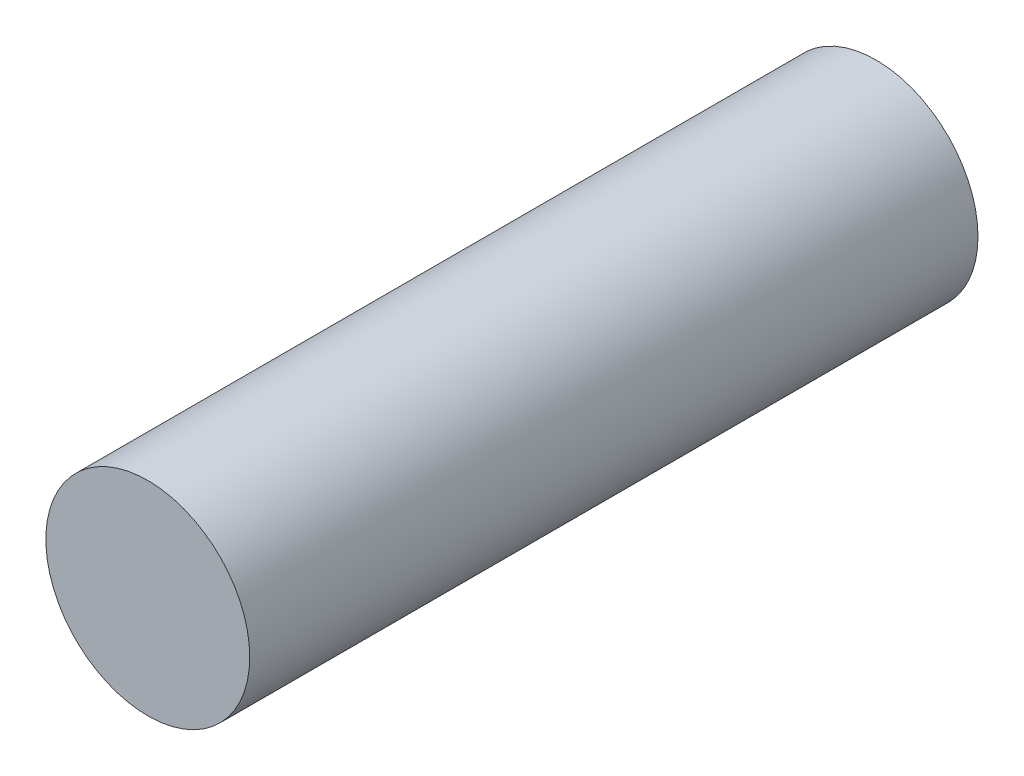
from build123d import *

# Parameters (mm, degrees)
SKETCH1_R           = 1.4
BOSS_EXTRUDE1_DEPTH = 10


with BuildPart() as part:
    # Sketch1 → Boss-Extrude1 (new body)
    with BuildSketch(Plane.XY):
        Circle(SKETCH1_R)
    extrude(amount=BOSS_EXTRUDE1_DEPTH)


solid = part.part
